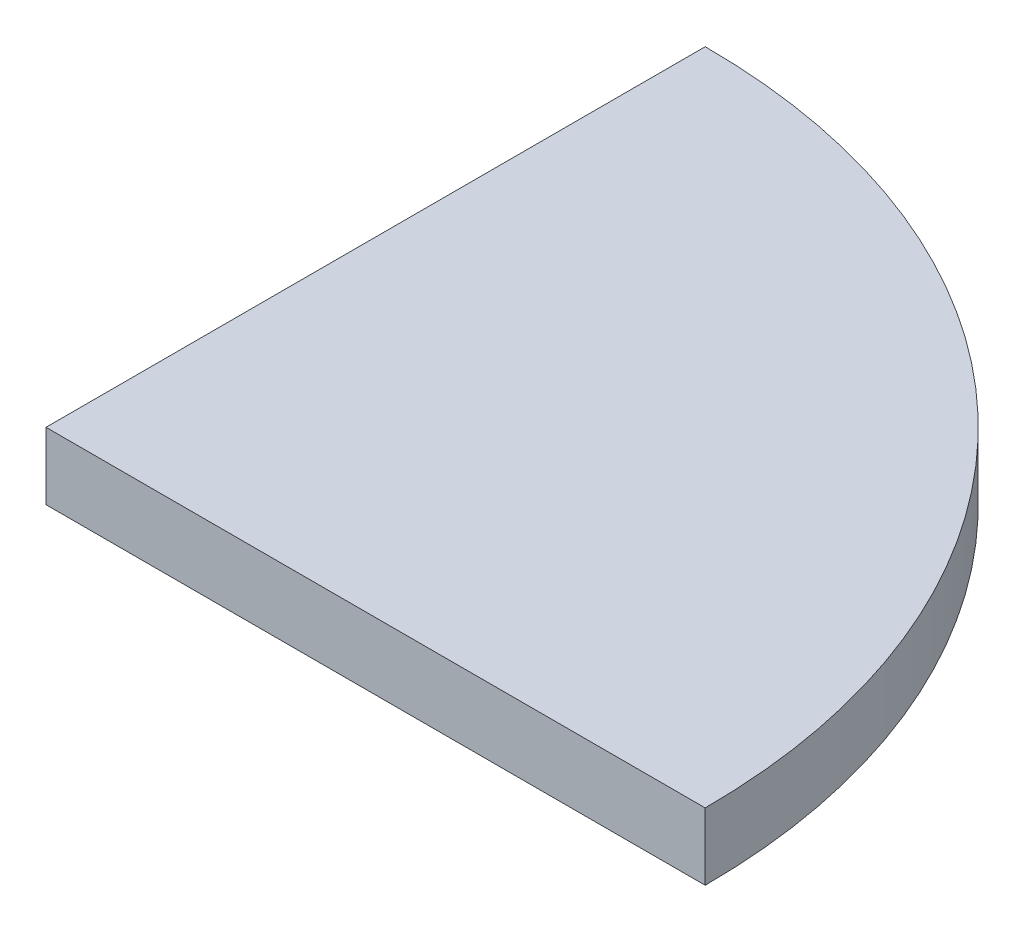
from build123d import *

# Parameters (mm, degrees)
BOSS_EXTRUDE1_DEPTH = 1.5


with BuildPart() as part:
    # Sketch1 → Boss-Extrude1 (new body)
    with BuildSketch(Plane(origin=(0, 0, 0), x_dir=(1, 0, 0), z_dir=(0, 1, 0))):
        with BuildLine():
            Line((0, 0), (14.75, 0))
            ThreePointArc((14.75, 0), (10.429825023, 10.429825023), (0, 14.75))
            Line((0, 14.75), (0, 0))
        make_face()
    extrude(amount=BOSS_EXTRUDE1_DEPTH)


solid = part.part
